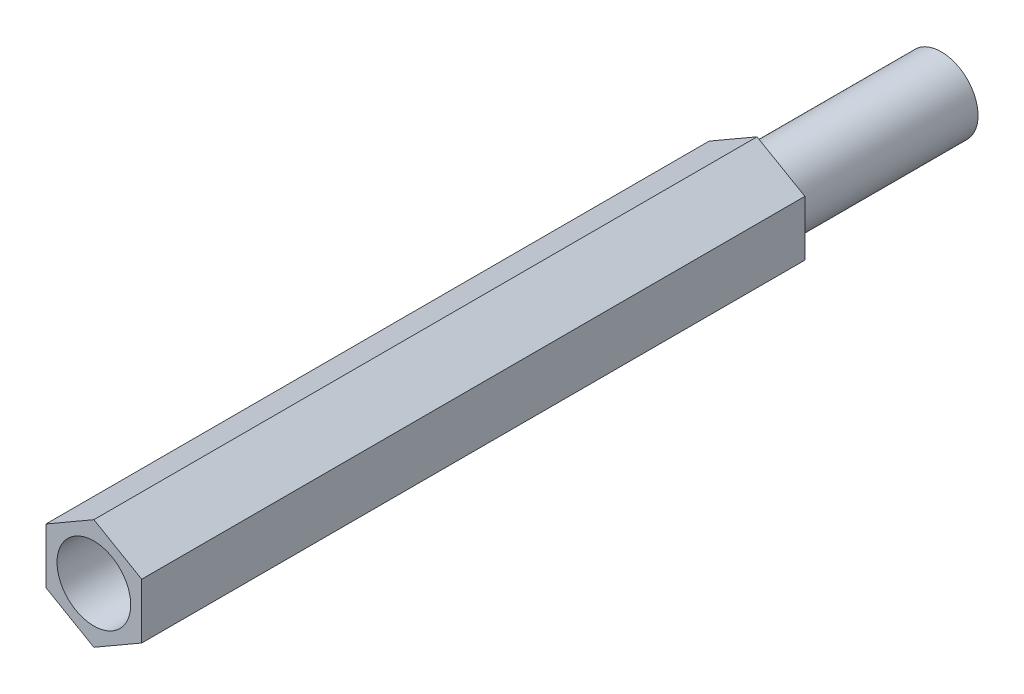
from build123d import *

# Parameters (mm, degrees)
BOSS_EXTRUDE1_DEPTH = 36
SKETCH2_R           = 2
CUT_EXTRUDE1_DEPTH  = 29
SKETCH3_R           = 2
BOSS_EXTRUDE2_DEPTH = 10


with BuildPart() as part:
    # Sketch1 → Boss-Extrude1 (new body)
    with BuildSketch(Plane.XY):
        Polygon((2.598076211, -1.5), (2.598076211, 1.5), (0, 3), (-2.598076211, 1.5), (-2.598076211, -1.5), (0, -3), align=None)
    extrude(amount=-BOSS_EXTRUDE1_DEPTH)

    # Sketch2 → Cut-Extrude1 (cut)
    with BuildSketch(Plane.XY):
        Circle(SKETCH2_R)
    extrude(amount=-CUT_EXTRUDE1_DEPTH, mode=Mode.SUBTRACT)

    # Sketch3 → Boss-Extrude2 (add)
    with BuildSketch(Plane(origin=(0, 0, -36), x_dir=(-1, 0, 0), z_dir=(0, 0, -1))):
        Circle(SKETCH3_R)
    extrude(amount=BOSS_EXTRUDE2_DEPTH)


solid = part.part
